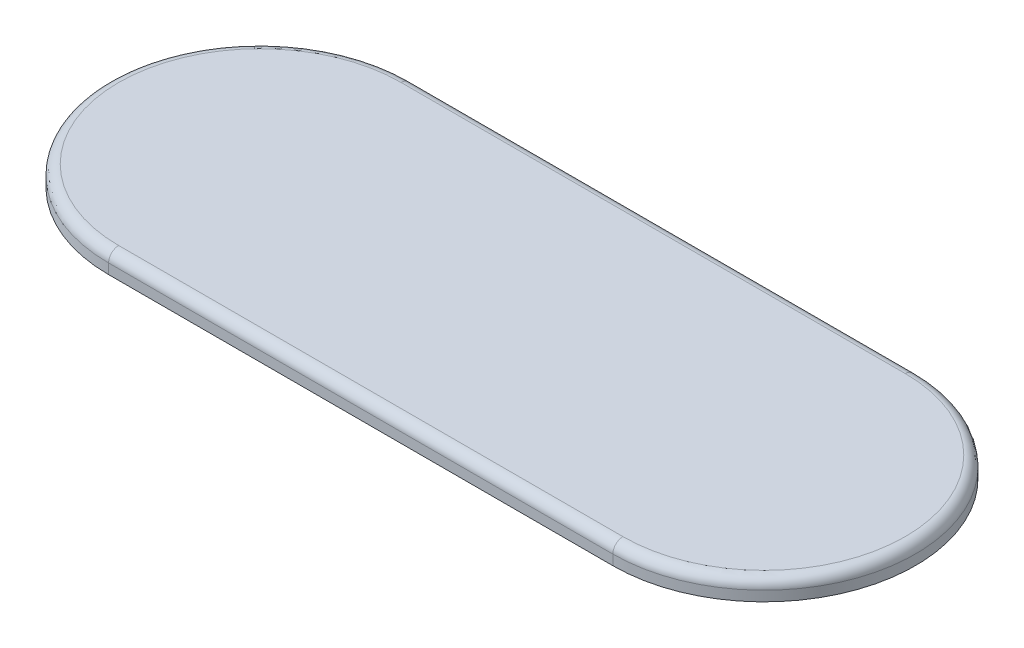
from build123d import *

# Parameters (mm, degrees)
BOSS_EXTRUDE1_DEPTH = 2
FILLET1_R           = 1


with BuildPart() as part:
    # Sketch1 → Boss-Extrude1 (new body)
    with BuildSketch(Plane(origin=(0, 0, 0), x_dir=(1, 0, 0), z_dir=(0, 1, 0))):
        with BuildLine():
            Line((0, 15), (50, 15))
            ThreePointArc((50, 15), (65, 0), (50, -15))
            Line((50, -15), (0, -15))
            ThreePointArc((0, -15), (-15, 0), (0, 15))
        make_face()
    extrude(amount=BOSS_EXTRUDE1_DEPTH)

    # Fillet1
    fillet1_edges = [part.edges().sort_by_distance(p)[0] for p in [
        (65, 2, 0),
        (25, 2, -15),
        (-15, 2, 0),
        (25, 2, 15),
    ]]
    fillet(fillet1_edges, radius=FILLET1_R)


solid = part.part
